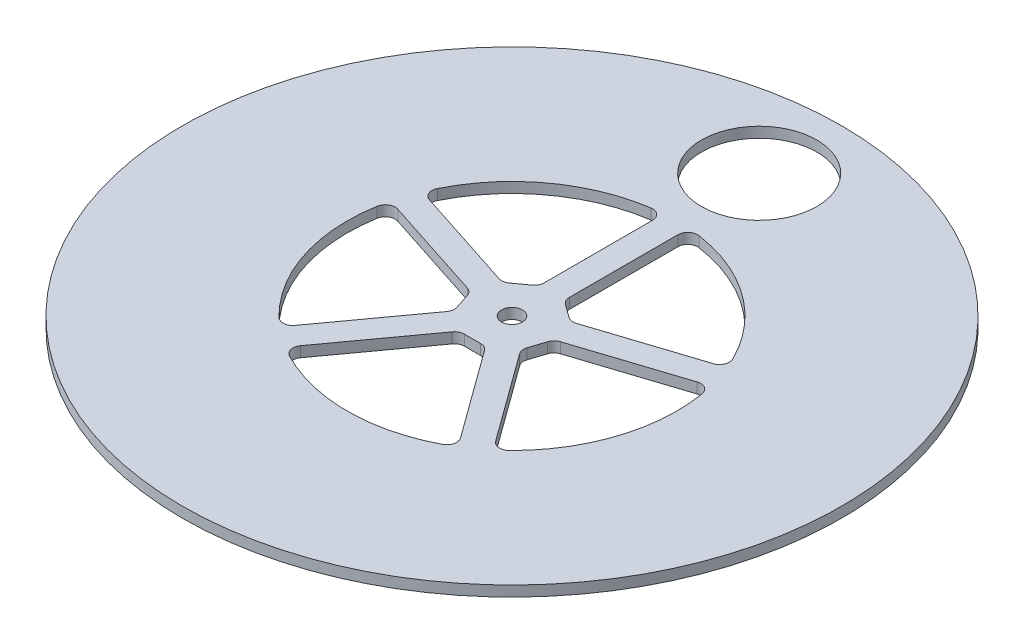
from build123d import *

# Parameters (mm, degrees)
SKETCH1_R                = 100
BOSS_EXTRUDE1_DEPTH      = 3.175
SKETCH2_R                = 17.5
CUT_EXTRUDE1_DEPTH       = 4.175
SKETCH3_R                = 3.175
CUT_EXTRUDE2_DEPTH       = 10
CUT_EXTRUDE3_DEPTH       = 3.175
FILLET1_R                = 3
CIRPATTERN1_COUNT        = 5
FILLET1_OF_CIRPATTERN1_R = 3


with BuildPart() as part:
    # Sketch1 → Boss-Extrude1 (new body)
    with BuildSketch(Plane(origin=(0, 0, 0), x_dir=(1, 0, 0), z_dir=(0, 1, 0))):
        Circle(SKETCH1_R)
    extrude(amount=BOSS_EXTRUDE1_DEPTH)

    # Sketch2 → Cut-Extrude1 (cut, through all)
    with BuildSketch(Plane(origin=(0, 3.175, 0), x_dir=(1, 0, 0), z_dir=(0, 1, 0))):
        with Locations((0, 75)):
            Circle(SKETCH2_R)
    extrude(amount=-CUT_EXTRUDE1_DEPTH, mode=Mode.SUBTRACT)

    # Sketch3 → Cut-Extrude2 (cut)
    with BuildSketch(Plane(origin=(0, 3.175, 0), x_dir=(1, 0, 0), z_dir=(0, 1, 0))):
        Circle(SKETCH3_R)
    extrude(amount=-CUT_EXTRUDE2_DEPTH, mode=Mode.SUBTRACT)

    # Sketch4 → Cut-Extrude3 (cut)
    with BuildSketch(Plane(origin=(0, 3.175, 0), x_dir=(1, 0, 0), z_dir=(0, 1, 0))):
        with BuildLine():
            Line((3.817355, 49.854065), (3.817355, 12.059345))
            Line((3.817355, 12.059345), (10.289491, 7.357063))
            Line((10.289491, 7.357063), (46.234406, 19.036274))
            ThreePointArc((46.234406, 19.036274), (29.389263, 40.45085), (3.817355, 49.854065))
        make_face()
    cut_extrude3 = extrude(amount=-CUT_EXTRUDE3_DEPTH, mode=Mode.SUBTRACT)

    # Fillet1
    fillet1_edges = [part.edges().sort_by_distance(p)[0] for p in [
        (3.817355, 1.5875, -49.854065),
        (46.234406, 1.5875, -19.036274),
        (10.289491, 1.5875, -7.357063),
        (3.817355, 1.5875, -12.059345),
    ]]
    fillet(fillet1_edges, radius=FILLET1_R)

    # CirPattern1: Cut-Extrude3 ×5 about axis
    cirpattern1_axis = Axis((0, 0, 0), (0, 1, 0))
    for i in range(1, CIRPATTERN1_COUNT):
        add(cut_extrude3.rotate(cirpattern1_axis, i * 360 / CIRPATTERN1_COUNT), mode=Mode.SUBTRACT)

    # Fillet1 of CirPattern1
    fillet1_of_cirpattern1_edges = [part.edges().sort_by_distance(p)[0] for p in [
        (-46.234406, 1.5875, -19.036274),
        (-3.817355, 1.5875, -49.854065),
        (-3.817355, 1.5875, -12.059345),
        (-10.289491, 1.5875, -7.357063),
        (-32.391789, 1.5875, 38.089001),
        (-48.593661, 1.5875, -11.775233),
        (-12.648746, 1.5875, -0.096022),
        (-10.17661, 1.5875, 7.51243),
        (26.215179, 1.5875, 42.576571),
        (-26.215179, 1.5875, 42.576571),
        (-4, 1.5875, 12),
        (4, 1.5875, 12),
        (48.593661, 1.5875, -11.775233),
        (32.391789, 1.5875, 38.089001),
        (10.17661, 1.5875, 7.51243),
        (12.648746, 1.5875, -0.096022),
    ]]
    fillet(fillet1_of_cirpattern1_edges, radius=FILLET1_OF_CIRPATTERN1_R)


solid = part.part
